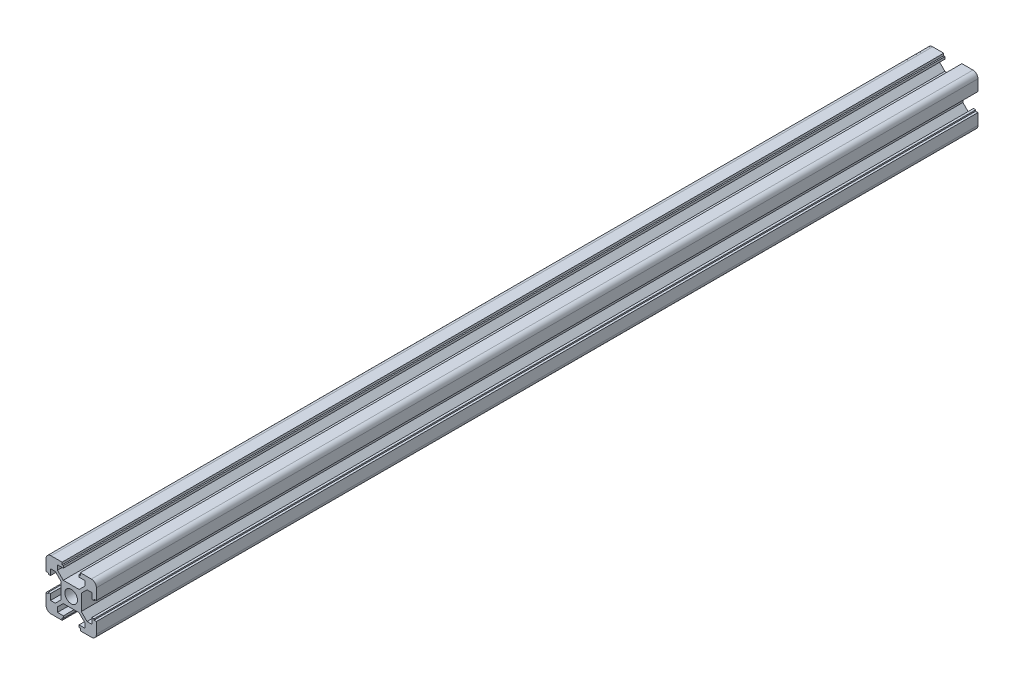
from build123d import *

# Parameters (mm, degrees)
SKETCH_1_R      = 2.5
EXTRUDE_1_DEPTH = 350
FILLET_1_R      = 2


with BuildPart() as part:
    # 草图1 → 凸台-拉伸1 (new body)
    with BuildSketch(Plane.XY):
        Polygon((-3.151471863, 4), (3.151471863, 4), (5.45, 6.298528137), (5.45, 8.2), (3.1, 8.2), (3.1, 9.1), (3.6, 9.1), (3.6, 10), (10, 10), (10, 3.6), (9.1, 3.6), (9.1, 3.1), (8.2, 3.1), (8.2, 5.45), (6.298528137, 5.45), (4, 3.151471863), (4, -3.151471863), (6.298528137, -5.45), (8.2, -5.45), (8.2, -3.1), (9.1, -3.1), (9.1, -3.6), (10, -3.6), (10, -10), (3.6, -10), (3.6, -9.1), (3.1, -9.1), (3.1, -8.2), (5.45, -8.2), (5.45, -6.298528137), (3.151471863, -4), (-3.151471863, -4), (-5.45, -6.298528137), (-5.45, -8.2), (-3.1, -8.2), (-3.1, -9.1), (-3.6, -9.1), (-3.6, -10), (-10, -10), (-10, -3.6), (-9.1, -3.6), (-9.1, -3.1), (-8.2, -3.1), (-8.2, -5.45), (-6.298528137, -5.45), (-4, -3.151471863), (-4, 3.151471863), (-6.298528137, 5.45), (-8.2, 5.45), (-8.2, 3.1), (-9.1, 3.1), (-9.1, 3.6), (-10, 3.6), (-10, 10), (-3.6, 10), (-3.6, 9.1), (-3.1, 9.1), (-3.1, 8.2), (-5.45, 8.2), (-5.45, 6.298528137), align=None)
        Circle(SKETCH_1_R, mode=Mode.SUBTRACT)
    extrude(amount=EXTRUDE_1_DEPTH)

    # 圆角1
    fillet_1_edges = [part.edges().sort_by_distance(p)[0] for p in [
        (10, -10, 175),
        (-10, -10, 175),
        (-10, 10, 175),
        (10, 10, 175),
    ]]
    fillet(fillet_1_edges, radius=FILLET_1_R)


solid = part.part
